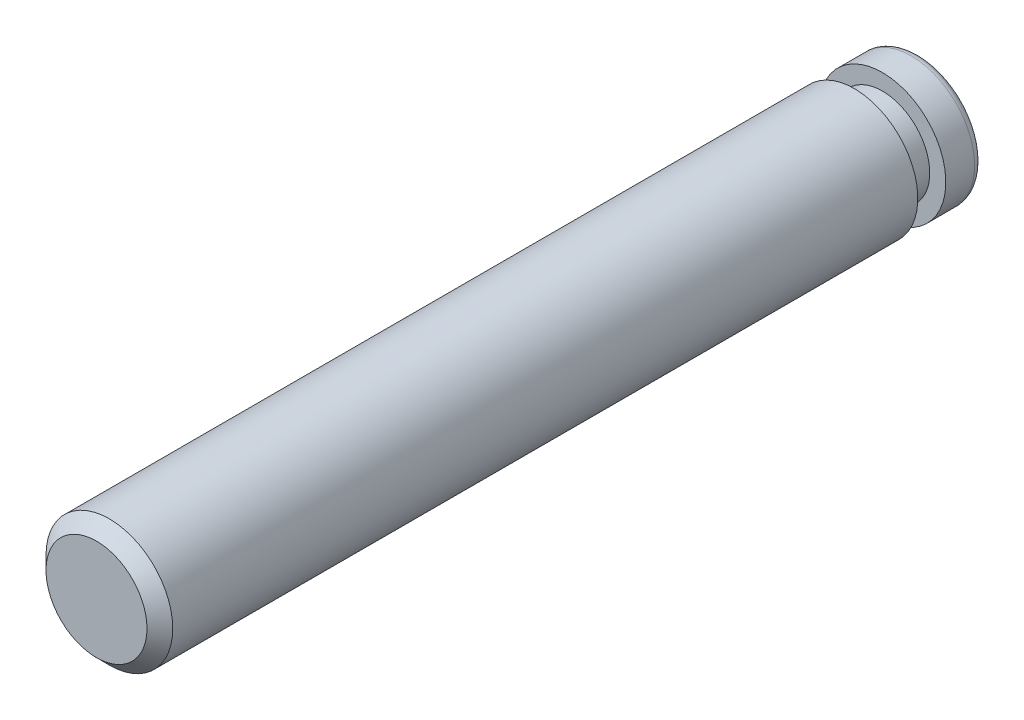
from build123d import *

# Parameters (mm, degrees)
SKETCH1_R      = 1.9558
EXTRUDE1_DEPTH = 12.7
SKETCH2_W      = 0.4953
SKETCH2_H      = 0.8636
FILLET1_R      = 0.254
CHAMFER1_SIZE  = 0.396875


with BuildPart() as part:
    # Sketch1 → Extrude1 (new body, symmetric)
    with BuildSketch(Plane.XY):
        Circle(SKETCH1_R)
    extrude(amount=EXTRUDE1_DEPTH, both=True)

    # Sketch2 → Cut-Revolve1 (revolve, cut)
    with BuildSketch(Plane(origin=(0, 0, 0), x_dir=(1, 0, 0), z_dir=(0, 1, 0))):
        with Locations((1.70815, 11.1252)):
            Rectangle(SKETCH2_W, SKETCH2_H)
    revolve(axis=Axis((0, 0, -10.042474892), (0, 0, 1)), mode=Mode.SUBTRACT)

    # Fillet1
    fillet1_edges = [part.edges().sort_by_distance(p)[0] for p in [
        (-1.9558, 0, -12.7),
    ]]
    fillet(fillet1_edges, radius=FILLET1_R)

    # Chamfer1
    chamfer1_edges = [part.edges().sort_by_distance(p)[0] for p in [
        (-1.9558, 0, 12.7),
    ]]
    chamfer(chamfer1_edges, length=CHAMFER1_SIZE)


solid = part.part
